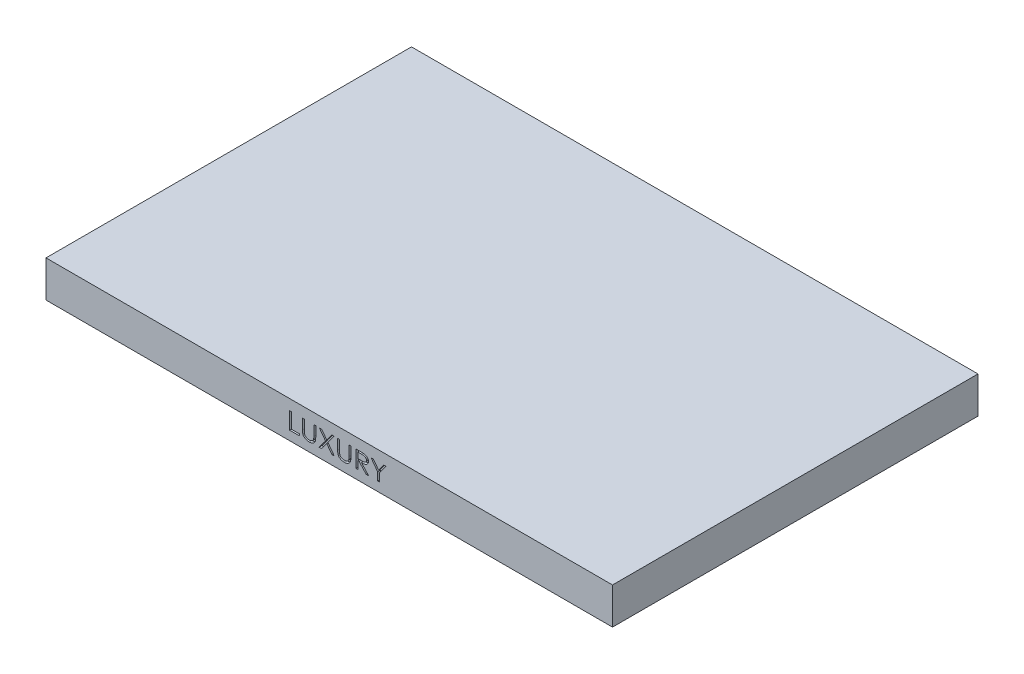
from build123d import *

# Parameters (mm, degrees)
SKETCH1_W           = 620
SKETCH1_H           = 400
BOSS_EXTRUDE3_DEPTH = 40
CUT_EXTRUDE1_DEPTH  = 3


with BuildPart() as part:
    # Sketch1 → Boss-Extrude3 (new body)
    with BuildSketch(Plane(origin=(0, 0, 0), x_dir=(1, 0, 0), z_dir=(0, 1, 0))):
        Rectangle(SKETCH1_W, SKETCH1_H)
    extrude(amount=-BOSS_EXTRUDE3_DEPTH)

    # Sketch2 → Cut-Extrude1 (cut)
    with BuildSketch(Plane.XY.offset(200)):
        Polygon((-43.263087607, -11.479166667), (-41.126068376, -11.479166667), (-41.126068376, -28.10042735), (-32.577991453, -28.10042735), (-32.577991453, -30), (-43.263087607, -30), align=None)
        with BuildLine():
            Line((-29.253739316, -11.479166667), (-27.116720085, -11.479166667))
            Line((-27.116720085, -11.479166667), (-27.116720085, -22.576084235))
            add(Edge.make_bspline(
                [(-27.116720085, -22.576084235), (-27.117689286, -22.733155992), (-27.11952861, -23.031242991), (-27.107242535, -23.455323063), (-27.108926434, -23.832712556), (-27.093627696, -24.163947729), (-27.087800078, -24.448884135), (-27.063833939, -24.6869177), (-27.055246382, -24.879712582), (-27.035977157, -24.991460874), (-27.027677618, -25.039592515)],
                knots=[0, 0, 0, 0, 0.000471183, 0.0008942, 0.001272649, 0.001603035, 0.00188893, 0.0021271, 0.002320595, 0.002466992, 0.002466992, 0.002466992, 0.002466992], degree=3))
            add(Edge.make_bspline(
                [(-27.027677618, -25.039592515), (-26.994687616, -25.213707852), (-26.93029302, -25.553571034), (-26.76704039, -26.035325794), (-26.544764069, -26.471702797), (-26.268100909, -26.86955059), (-25.915395065, -27.223826878), (-25.492656851, -27.549229041), (-24.984101441, -27.835737684), (-24.413307466, -28.093734577), (-23.799335137, -28.304833074), (-23.171577815, -28.461679537), (-22.540265702, -28.558927994), (-22.118310556, -28.569863298), (-21.90773571, -28.575320513)],
                knots=[0, 0, 0, 0, 0.000531206, 0.001036884, 0.001519725, 0.00199631, 0.002484298, 0.003013401, 0.003591856, 0.004231136, 0.004890533, 0.005536613, 0.006170444, 0.006801859, 0.006801859, 0.006801859, 0.006801859], degree=3))
            add(Edge.make_bspline(
                [(-21.90773571, -28.575320513), (-21.726998162, -28.569618172), (-21.366660218, -28.558249367), (-20.831658827, -28.488647286), (-20.310247473, -28.362578065), (-19.802540013, -28.19984353), (-19.325271621, -27.983449167), (-18.878566964, -27.737949071), (-18.480853816, -27.443418623), (-18.117473028, -27.121966911), (-17.79877208, -26.758539948), (-17.529478923, -26.357318819), (-17.301522398, -25.920698719), (-17.189834409, -25.609988093), (-17.132833367, -25.451413929)],
                knots=[0, 0, 0, 0, 0.000542297, 0.001081182, 0.001614831, 0.002149833, 0.002677972, 0.003184643, 0.003675906, 0.004159331, 0.004637833, 0.005121472, 0.005606006, 0.006111044, 0.006111044, 0.006111044, 0.006111044], degree=3))
            add(Edge.make_bspline(
                [(-17.132833367, -25.451413929), (-17.114760106, -25.386060726), (-17.074508784, -25.240511298), (-17.026675208, -24.995308319), (-16.993923083, -24.703525933), (-16.957268698, -24.367513762), (-16.939126979, -23.984755989), (-16.918951996, -23.555731408), (-16.908552631, -23.080705841), (-16.907215508, -22.749225176), (-16.906517094, -22.576084235)],
                knots=[0, 0, 0, 0, 0.00020338, 0.000452952, 0.000748389, 0.001083963, 0.001466752, 0.001897523, 0.002372547, 0.002891974, 0.002891974, 0.002891974, 0.002891974], degree=3))
            Line((-16.906517094, -22.576084235), (-16.906517094, -11.479166667))
            Line((-16.906517094, -11.479166667), (-14.769497863, -11.479166667))
            Line((-14.769497863, -11.479166667), (-14.769497863, -22.665126703))
            add(Edge.make_bspline(
                [(-14.769497863, -22.665126703), (-14.770114217, -22.866760262), (-14.77131741, -23.260372019), (-14.804218628, -23.836788853), (-14.846165132, -24.383988947), (-14.908913597, -24.901534039), (-14.991598459, -25.387562656), (-15.085404652, -25.846912289), (-15.205225278, -26.274621024), (-15.337907628, -26.677759047), (-15.498942442, -27.058918094), (-15.697093794, -27.423688356), (-15.930965674, -27.775965992), (-16.201909328, -28.115621988), (-16.503500272, -28.446688533), (-16.850187039, -28.756727055), (-17.223581863, -29.062975702), (-17.633351548, -29.350471605), (-18.072973176, -29.613274922), (-18.538317965, -29.843608945), (-19.024199724, -30.040292866), (-19.53361719, -30.202186257), (-20.066697511, -30.321393942), (-20.621492127, -30.411947579), (-21.198125349, -30.463575902), (-21.58980474, -30.471077737), (-21.78901242, -30.474893162)],
                knots=[0, 0, 0, 0, 0.000604792, 0.001180624, 0.001731521, 0.002251068, 0.002743897, 0.003210324, 0.003656771, 0.004075619, 0.004482886, 0.004896242, 0.005319161, 0.005749677, 0.006198661, 0.006660863, 0.007143533, 0.007646864, 0.008160978, 0.008678653, 0.009202947, 0.009732141, 0.010280245, 0.010840176, 0.011417583, 0.012015197, 0.012015197, 0.012015197, 0.012015197], degree=3))
            add(Edge.make_bspline(
                [(-21.78901242, -30.474893162), (-22.005497783, -30.470691454), (-22.43157824, -30.462421769), (-23.058914796, -30.416257981), (-23.661458265, -30.328103925), (-24.242636859, -30.216490153), (-24.797964208, -30.062058988), (-25.332695166, -29.882185516), (-25.839678333, -29.661703118), (-26.322827183, -29.414260164), (-26.773285864, -29.137852566), (-27.187352671, -28.836001137), (-27.563898688, -28.512676231), (-27.901519791, -28.167654426), (-28.203000002, -27.802337814), (-28.456819908, -27.410524266), (-28.680305025, -27.001188427), (-28.795298887, -26.712921196), (-28.85304821, -26.568154881)],
                knots=[0, 0, 0, 0, 0.000649533, 0.001278393, 0.001885457, 0.00247555, 0.00305248, 0.003613307, 0.004166722, 0.004709324, 0.005240646, 0.005750458, 0.00624503, 0.006727771, 0.007197125, 0.007663271, 0.00812638, 0.008593574, 0.008593574, 0.008593574, 0.008593574], degree=3))
            add(Edge.make_bspline(
                [(-28.85304821, -26.568154881), (-28.885546694, -26.46966459), (-28.955855237, -26.256586684), (-29.033581779, -25.902222242), (-29.104474907, -25.495154149), (-29.157566991, -25.032935758), (-29.20281634, -24.518374639), (-29.23025549, -23.949057355), (-29.249228832, -23.325653665), (-29.252193775, -22.891459791), (-29.253739316, -22.665126703)],
                knots=[0, 0, 0, 0, 0.000310963, 0.000672751, 0.001086905, 0.001550312, 0.002067934, 0.002636355, 0.003259929, 0.003938918, 0.003938918, 0.003938918, 0.003938918], degree=3))
            Line((-29.253739316, -22.665126703), (-29.253739316, -11.479166667))
        make_face()
        Polygon((-10.851629274, -11.479166667), (-8.313918937, -11.479166667), (-2.778445513, -18.884531918), (2.757027911, -11.479166667), (5.294738248, -11.479166667), (-1.509590345, -20.580048912), (5.532184829, -30), (2.994474493, -30), (-2.778445513, -22.279276008), (-8.551365518, -30), (-11.089075855, -30), (-4.047300681, -20.580048912), align=None)
        with BuildLine():
            Line((9.212606838, -11.479166667), (11.349626068, -11.479166667))
            Line((11.349626068, -11.479166667), (11.349626068, -22.576084235))
            add(Edge.make_bspline(
                [(11.349626068, -22.576084235), (11.348656868, -22.733155992), (11.346817544, -23.031242991), (11.359103619, -23.455323063), (11.35741972, -23.832712556), (11.372718458, -24.163947729), (11.378546075, -24.448884135), (11.402512214, -24.6869177), (11.411099772, -24.879712582), (11.430368997, -24.991460874), (11.438668536, -25.039592515)],
                knots=[0, 0, 0, 0, 0.000471183, 0.0008942, 0.001272649, 0.001603035, 0.00188893, 0.0021271, 0.002320595, 0.002466992, 0.002466992, 0.002466992, 0.002466992], degree=3))
            add(Edge.make_bspline(
                [(11.438668536, -25.039592515), (11.471658538, -25.213707852), (11.536053133, -25.553571034), (11.699305764, -26.035325794), (11.921582085, -26.471702797), (12.198245245, -26.86955059), (12.550951088, -27.223826878), (12.973689302, -27.549229041), (13.482244713, -27.835737684), (14.053038688, -28.093734577), (14.667011017, -28.304833074), (15.294768339, -28.461679537), (15.926080452, -28.558927994), (16.348035598, -28.569863298), (16.558610443, -28.575320513)],
                knots=[0, 0, 0, 0, 0.000531206, 0.001036884, 0.001519725, 0.00199631, 0.002484298, 0.003013401, 0.003591856, 0.004231136, 0.004890533, 0.005536613, 0.006170444, 0.006801859, 0.006801859, 0.006801859, 0.006801859], degree=3))
            add(Edge.make_bspline(
                [(16.558610443, -28.575320513), (16.739347992, -28.569618172), (17.099685936, -28.558249367), (17.634687327, -28.488647286), (18.15609868, -28.362578065), (18.663806141, -28.19984353), (19.141074533, -27.983449167), (19.58777919, -27.737949071), (19.985492338, -27.443418623), (20.348873126, -27.121966911), (20.667574073, -26.758539948), (20.936867231, -26.357318819), (21.164823756, -25.920698719), (21.276511745, -25.609988093), (21.333512787, -25.451413929)],
                knots=[0, 0, 0, 0, 0.000542297, 0.001081182, 0.001614831, 0.002149833, 0.002677972, 0.003184643, 0.003675906, 0.004159331, 0.004637833, 0.005121472, 0.005606006, 0.006111044, 0.006111044, 0.006111044, 0.006111044], degree=3))
            add(Edge.make_bspline(
                [(21.333512787, -25.451413929), (21.351586048, -25.386060726), (21.391837369, -25.240511298), (21.439670946, -24.995308319), (21.472423071, -24.703525933), (21.509077456, -24.367513762), (21.527219175, -23.984755989), (21.547394158, -23.555731408), (21.557793523, -23.080705841), (21.559130646, -22.749225176), (21.55982906, -22.576084235)],
                knots=[0, 0, 0, 0, 0.00020338, 0.000452952, 0.000748389, 0.001083963, 0.001466752, 0.001897523, 0.002372547, 0.002891974, 0.002891974, 0.002891974, 0.002891974], degree=3))
            Line((21.55982906, -22.576084235), (21.55982906, -11.479166667))
            Line((21.55982906, -11.479166667), (23.696848291, -11.479166667))
            Line((23.696848291, -11.479166667), (23.696848291, -22.665126703))
            add(Edge.make_bspline(
                [(23.696848291, -22.665126703), (23.696231937, -22.866760262), (23.695028744, -23.260372019), (23.662127526, -23.836788853), (23.620181022, -24.383988947), (23.557432557, -24.901534039), (23.474747694, -25.387562656), (23.380941502, -25.846912289), (23.261120876, -26.274621024), (23.128438526, -26.677759047), (22.967403712, -27.058918094), (22.76925236, -27.423688356), (22.53538048, -27.775965992), (22.264436826, -28.115621988), (21.962845882, -28.446688533), (21.616159115, -28.756727055), (21.242764291, -29.062975702), (20.832994606, -29.350471605), (20.393372977, -29.613274922), (19.928028189, -29.843608945), (19.44214643, -30.040292866), (18.932728964, -30.202186257), (18.399648642, -30.321393942), (17.844854027, -30.411947579), (17.268220804, -30.463575902), (16.876541414, -30.471077737), (16.677333734, -30.474893162)],
                knots=[0, 0, 0, 0, 0.000604792, 0.001180624, 0.001731521, 0.002251068, 0.002743897, 0.003210324, 0.003656771, 0.004075619, 0.004482886, 0.004896242, 0.005319161, 0.005749677, 0.006198661, 0.006660863, 0.007143533, 0.007646864, 0.008160978, 0.008678653, 0.009202947, 0.009732141, 0.010280245, 0.010840176, 0.011417583, 0.012015197, 0.012015197, 0.012015197, 0.012015197], degree=3))
            add(Edge.make_bspline(
                [(16.677333734, -30.474893162), (16.460848371, -30.470691454), (16.034767914, -30.462421769), (15.407431358, -30.416257981), (14.804887889, -30.328103925), (14.223709295, -30.216490153), (13.668381946, -30.062058988), (13.133650988, -29.882185516), (12.626667821, -29.661703118), (12.143518971, -29.414260164), (11.69306029, -29.137852566), (11.278993483, -28.836001137), (10.902447466, -28.512676231), (10.564826363, -28.167654426), (10.263346152, -27.802337814), (10.009526246, -27.410524266), (9.786041129, -27.001188427), (9.671047267, -26.712921196), (9.613297943, -26.568154881)],
                knots=[0, 0, 0, 0, 0.000649533, 0.001278393, 0.001885457, 0.00247555, 0.00305248, 0.003613307, 0.004166722, 0.004709324, 0.005240646, 0.005750458, 0.00624503, 0.006727771, 0.007197125, 0.007663271, 0.00812638, 0.008593574, 0.008593574, 0.008593574, 0.008593574], degree=3))
            add(Edge.make_bspline(
                [(9.613297943, -26.568154881), (9.58079946, -26.46966459), (9.510490917, -26.256586684), (9.432764375, -25.902222242), (9.361871247, -25.495154149), (9.308779162, -25.032935758), (9.263529814, -24.518374639), (9.236090664, -23.949057355), (9.217117322, -23.325653665), (9.214152379, -22.891459791), (9.212606838, -22.665126703)],
                knots=[0, 0, 0, 0, 0.000310963, 0.000672751, 0.001086905, 0.001550312, 0.002067934, 0.002636355, 0.003259929, 0.003938918, 0.003938918, 0.003938918, 0.003938918], degree=3))
            Line((9.212606838, -22.665126703), (9.212606838, -11.479166667))
        make_face()
        with BuildLine():
            Line((29.158119658, -11.479166667), (33.543461205, -11.479166667))
            add(Edge.make_bspline(
                [(33.543461205, -11.479166667), (33.836557801, -11.479989953), (34.399276926, -11.481570589), (35.205759867, -11.490387649), (35.939000557, -11.515694719), (36.597324401, -11.537200542), (37.182067693, -11.577363748), (37.692245153, -11.614272334), (38.129269735, -11.665210202), (38.393954846, -11.710666066), (38.514998998, -11.731453659)],
                knots=[0, 0, 0, 0, 0.000879302, 0.001688181, 0.00241941, 0.003080319, 0.003663986, 0.004177604, 0.004614782, 0.004983186, 0.004983186, 0.004983186, 0.004983186], degree=3))
            add(Edge.make_bspline(
                [(38.514998998, -11.731453659), (38.675120553, -11.764918314), (38.990792062, -11.830892182), (39.44660497, -11.969563593), (39.879889469, -12.134300982), (40.292494612, -12.321026923), (40.679351143, -12.542240302), (41.044098612, -12.787513407), (41.387989885, -13.058902631), (41.703431505, -13.358825999), (41.996451299, -13.675140426), (42.243133865, -14.019017741), (42.458273074, -14.375894396), (42.628716883, -14.753903751), (42.762514274, -15.147908443), (42.859225044, -15.560274227), (42.920605265, -15.990034735), (42.926856262, -16.283541087), (42.930021368, -16.432153946)],
                knots=[0, 0, 0, 0, 0.000490548, 0.00096709, 0.001427382, 0.001880592, 0.00232421, 0.002762567, 0.003198295, 0.003636606, 0.004067361, 0.004489613, 0.004903834, 0.005315588, 0.005730921, 0.006150278, 0.006584724, 0.007030323, 0.007030323, 0.007030323, 0.007030323], degree=3))
            add(Edge.make_bspline(
                [(42.930021368, -16.432153946), (42.926549172, -16.55712778), (42.919693073, -16.803897548), (42.883911484, -17.169050661), (42.816251627, -17.521115816), (42.723645298, -17.862911976), (42.600341031, -18.190629552), (42.455118201, -18.510554471), (42.280895842, -18.816887098), (42.080317617, -19.111417773), (41.852493029, -19.387641429), (41.608497116, -19.654398538), (41.336023154, -19.898010761), (41.042067828, -20.126751862), (40.721633298, -20.331544131), (40.383218843, -20.527767864), (40.018901794, -20.700331854), (39.630466094, -20.858138614), (39.210932707, -20.994490866), (38.75860544, -21.118799367), (38.266891795, -21.215401475), (37.738858343, -21.302270129), (37.171740054, -21.367533726), (36.566612167, -21.415178805), (35.92440831, -21.445162364), (35.483878225, -21.449628384), (35.257528713, -21.451923077)],
                knots=[0, 0, 0, 0, 0.000375014, 0.000740492, 0.001099223, 0.001449351, 0.001801518, 0.002148487, 0.002502369, 0.002857397, 0.00321607, 0.003575721, 0.003940841, 0.004311146, 0.004691897, 0.00508075, 0.005483993, 0.00590012, 0.006337739, 0.006806638, 0.007306512, 0.007840212, 0.008411773, 0.00901844, 0.009660974, 0.010340014, 0.010340014, 0.010340014, 0.010340014], degree=3))
            Line((35.257528713, -21.451923077), (43.167467949, -30))
            Line((43.167467949, -30), (40.459092882, -30))
            Line((40.459092882, -30), (32.549153646, -21.451923077))
            Line((32.549153646, -21.451923077), (31.295138889, -21.451923077))
            Line((31.295138889, -21.451923077), (31.295138889, -30))
            Line((31.295138889, -30), (29.158119658, -30))
            Line((29.158119658, -30), (29.158119658, -11.479166667))
        make_face()
        with BuildLine():
            Line((31.295138889, -13.378739316), (31.295138889, -19.552350427))
            Line((31.295138889, -19.552350427), (35.172196347, -19.578321147))
            add(Edge.make_bspline(
                [(35.172196347, -19.578321147), (35.354017265, -19.57840803), (35.705399224, -19.578575938), (36.213679566, -19.557349299), (36.685156917, -19.533473576), (37.119526052, -19.496655288), (37.518042963, -19.448656233), (37.879830147, -19.390902786), (38.205614563, -19.320309937), (38.584944435, -19.214323005), (39.009498589, -19.048308609), (39.4675591, -18.798507837), (39.863290599, -18.492960554), (40.196560167, -18.138411291), (40.458991826, -17.746102554), (40.652656052, -17.32744241), (40.77289363, -16.885259181), (40.786273826, -16.581294353), (40.793002137, -16.428443843)],
                knots=[0, 0, 0, 0, 0.000545398, 0.00105402, 0.001525918, 0.001961583, 0.002361483, 0.002729887, 0.003060274, 0.003360953, 0.003910749, 0.004423898, 0.004921107, 0.005404077, 0.005877417, 0.006330627, 0.006783274, 0.007241123, 0.007241123, 0.007241123, 0.007241123], degree=3))
            add(Edge.make_bspline(
                [(40.793002137, -16.428443843), (40.786254938, -16.279287109), (40.772833996, -15.982597487), (40.652307098, -15.549752273), (40.456000747, -15.140381423), (40.186367821, -14.75942366), (39.859667953, -14.412145951), (39.475311439, -14.116430777), (39.044725642, -13.873542715), (38.645465767, -13.717740857), (38.289254789, -13.622369101), (37.978848791, -13.554526078), (37.626869016, -13.50043974), (37.233058601, -13.457592252), (36.798967384, -13.419697594), (36.322580519, -13.394734792), (35.805486123, -13.37986424), (35.446754894, -13.379122766), (35.261238815, -13.378739316)],
                knots=[0, 0, 0, 0, 0.000446756, 0.000888647, 0.00133671, 0.00180296, 0.002283228, 0.002761889, 0.003251988, 0.003761827, 0.004042645, 0.004357742, 0.004714568, 0.005110351, 0.005546016, 0.006021618, 0.006541245, 0.007097773, 0.007097773, 0.007097773, 0.007097773], degree=3))
            Line((35.261238815, -13.378739316), (31.295138889, -13.378739316))
        make_face(mode=Mode.SUBTRACT)
        Polygon((45.779380342, -11.479166667), (48.291119959, -11.479166667), (53.971287393, -19.229571481), (59.651454828, -11.479166667), (62.163194444, -11.479166667), (55.039797009, -21.195925982), (55.039797009, -30), (52.902777778, -30), (52.902777778, -21.195925982), align=None)
    extrude(amount=-CUT_EXTRUDE1_DEPTH, mode=Mode.SUBTRACT)


solid = part.part
